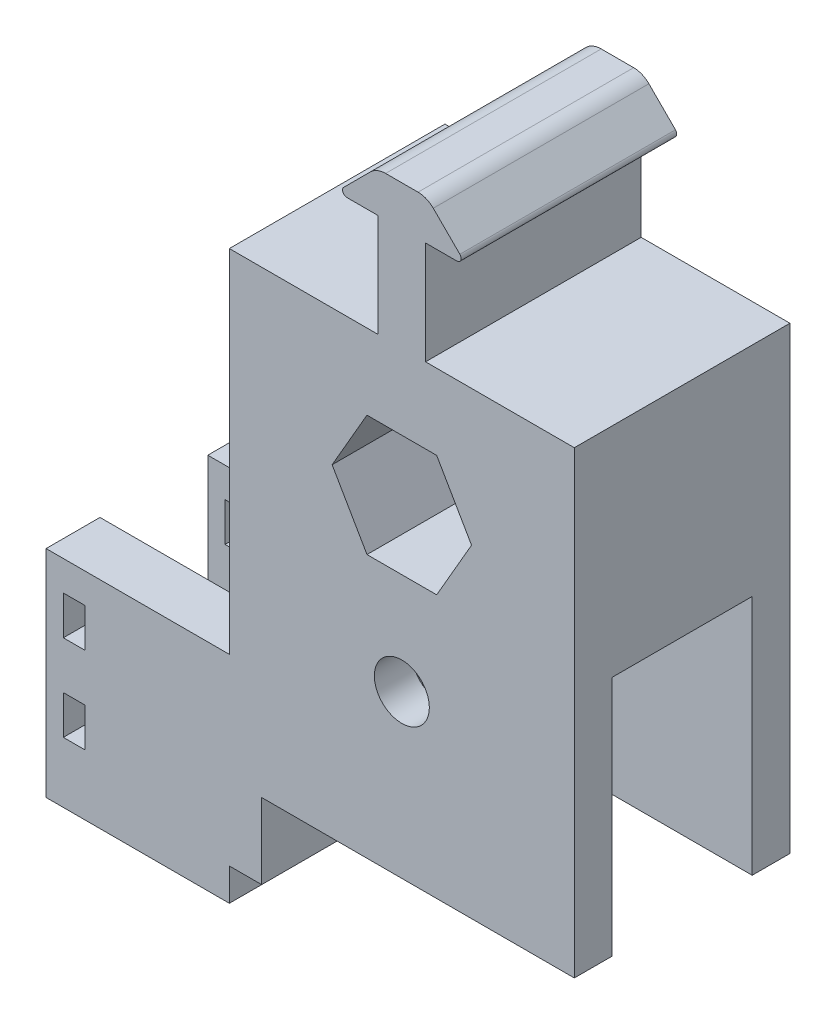
from build123d import *

# Parameters (mm, degrees)
BOSS_EXTRUDE1_DEPTH             = 12.7
BOSS_EXTRUDE4_REACH             = 14.7
BOSS_EXTRUDE4_DIRECTION_2_REACH = 14.7
SKETCH6_W                       = 16.51
SKETCH6_H                       = 15.748
CUT_EXTRUDE2_DEPTH              = 63.23
SKETCH11_W                      = 21.59
SKETCH11_H                      = 7.62
CUT_EXTRUDE3_DEPTH              = 3.81
SKETCH15_R                      = 3.2385
CUT_EXTRUDE4_DEPTH              = 25.4
SKETCH16_W                      = 16.51
SKETCH16_H                      = 12.7
CUT_EXTRUDE5_DEPTH              = 36.83
BOSS_EXTRUDE5_DEPTH             = 5.08
SKETCH18_W                      = 6.35
SKETCH18_H                      = 21.59
BOSS_EXTRUDE6_DEPTH             = 16.51
SKETCH22_W                      = 3.81
SKETCH22_H                      = 3.81
CUT_EXTRUDE6_DEPTH              = 25.4
SKETCH23_W                      = 2.54
SKETCH23_H                      = 4.572
CUT_EXTRUDE7_DEPTH              = 26.4


with BuildPart() as part:
    # Sketch1 → Boss-Extrude1 (new body, symmetric)
    with BuildSketch(Plane.XY):
        with BuildLine():
            Line((-20.32, 16.002), (-20.32, -38.1))
            Line((-20.32, -38.1), (20.32, -38.1))
            Line((20.32, -38.1), (20.32, 16.002))
            Line((20.32, 16.002), (2.794, 16.002))
            Line((2.794, 16.002), (2.794, 28.1305))
            Line((2.794, 28.1305), (6.477, 28.1305))
            ThreePointArc((6.477, 28.1305), (6.946330803, 28.444096816), (6.836210245, 28.997710245))
            Line((6.836210245, 28.997710245), (3.706459265, 32.127461224))
            ThreePointArc((3.706459265, 32.127461224), (2.882423959, 32.678064013), (1.910408041, 32.87141))
            Line((1.910408041, 32.87141), (-1.910408041, 32.87141))
            ThreePointArc((-1.910408041, 32.87141), (-2.882423959, 32.678064013), (-3.706459265, 32.127461224))
            Line((-3.706459265, 32.127461224), (-6.836210245, 28.997710245))
            ThreePointArc((-6.836210245, 28.997710245), (-6.946330803, 28.444096816), (-6.477, 28.1305))
            Line((-6.477, 28.1305), (-2.794, 28.1305))
            Line((-2.794, 28.1305), (-2.794, 16.002))
            Line((-2.794, 16.002), (-20.32, 16.002))
        make_face()
        Polygon((-4.106115114, 7.112), (-8.212230229, 0), (-4.106115114, -7.112), (4.106115114, -7.112), (8.212230229, 0), (4.106115114, 7.112), align=None, mode=Mode.SUBTRACT)
    extrude(amount=BOSS_EXTRUDE1_DEPTH, both=True)

    # Boss-Extrude4: up to this face of the body (flat: up to its plane)
    boss_extrude4_end = Plane(part.part.faces().sort_by_distance((0, -9.949298675, 12.7))[0])
    # Sketch10 → Boss-Extrude4 (add, up to the picked face)
    with BuildSketch(Plane.XY, mode=Mode.PRIVATE) as boss_extrude4_sk1:
        Polygon((-20.32, -38.1), (-20.32, -46.99), (-41.91, -46.99), (-41.91, -50.8), (-16.51, -50.8), (-16.51, -38.1), align=None)
    boss_extrude4_tool1 = split(extrude(boss_extrude4_sk1.sketch, amount=BOSS_EXTRUDE4_REACH, mode=Mode.PRIVATE), bisect_by=boss_extrude4_end, keep=Keep.BOTH, mode=Mode.PRIVATE)
    add(boss_extrude4_tool1.solids().sort_by_distance((-26.411296, -47.248704, 0))[0])

    # Boss-Extrude4 direction 2: up to this face of the body (flat: up to its plane)
    boss_extrude4_direction_2_end = Plane(part.part.faces().sort_by_distance((0, -9.949298675, -12.7))[0])
    # Sketch10 → Boss-Extrude4 direction 2 (add, up to the picked face)
    with BuildSketch(Plane.XY, mode=Mode.PRIVATE) as boss_extrude4_direction_2_sk1:
        Polygon((-20.32, -38.1), (-20.32, -46.99), (-41.91, -46.99), (-41.91, -50.8), (-16.51, -50.8), (-16.51, -38.1), align=None)
    boss_extrude4_direction_2_tool1 = split(extrude(boss_extrude4_direction_2_sk1.sketch, amount=-BOSS_EXTRUDE4_DIRECTION_2_REACH, mode=Mode.PRIVATE), bisect_by=boss_extrude4_direction_2_end, keep=Keep.BOTH, mode=Mode.PRIVATE)
    add(boss_extrude4_direction_2_tool1.solids().sort_by_distance((-26.411296, -47.248704, 0))[0])

    # Sketch6 → Cut-Extrude2 (cut, through all)
    with BuildSketch(Plane(origin=(20.32, 0, 0), x_dir=(0, 0, -1), z_dir=(1, 0, 0))):
        with Locations((0, -17.526)):
            Rectangle(SKETCH6_W, SKETCH6_H)
    extrude(amount=-CUT_EXTRUDE2_DEPTH, mode=Mode.SUBTRACT)

    # Sketch11 → Cut-Extrude3 (cut)
    with BuildSketch(Plane(origin=(0, -46.99, 0), x_dir=(1, 0, 0), z_dir=(0, 1, 0))):
        with Locations((-31.115, 0)):
            Rectangle(SKETCH11_W, SKETCH11_H)
    extrude(amount=-CUT_EXTRUDE3_DEPTH, mode=Mode.SUBTRACT)

    # Sketch15 → Cut-Extrude4 (cut)
    with BuildSketch(Plane.XY.offset(12.7)):
        with Locations((0, -19.05)):
            Circle(SKETCH15_R)
    extrude(amount=-CUT_EXTRUDE4_DEPTH, mode=Mode.SUBTRACT)

    # Sketch16 → Cut-Extrude5 (cut)
    with BuildSketch(Plane(origin=(20.32, 0, 0), x_dir=(0, 0, -1), z_dir=(1, 0, 0))):
        with Locations((0, -31.75)):
            Rectangle(SKETCH16_W, SKETCH16_H)
    extrude(amount=-CUT_EXTRUDE5_DEPTH, mode=Mode.SUBTRACT)

    # Sketch17 → Boss-Extrude5 (add)
    with BuildSketch(Plane.ZY.offset(20.32)):
        Polygon((12.7, -25.4), (12.7, -46.99), (3.81, -46.99), (3.81, -50.8), (-3.81, -50.8), (-3.81, -46.99), (-12.7, -46.99), (-12.7, -25.4), align=None)
    extrude(amount=BOSS_EXTRUDE5_DEPTH)

    # Sketch18 → Boss-Extrude6 (add)
    with BuildSketch(Plane.ZY.offset(25.4)):
        with Locations((-9.525, -36.195)):
            Rectangle(SKETCH18_W, SKETCH18_H)
        with Locations((9.525, -36.195)):
            Rectangle(SKETCH18_W, SKETCH18_H)
    extrude(amount=BOSS_EXTRUDE6_DEPTH)

    # Sketch22 → Cut-Extrude6 (cut)
    with BuildSketch(Plane.XY.offset(12.7)):
        with Locations((-18.415, -48.895)):
            Rectangle(SKETCH22_W, SKETCH22_H)
    extrude(amount=-CUT_EXTRUDE6_DEPTH, mode=Mode.SUBTRACT)

    # Sketch23 → Cut-Extrude7 (cut, through all)
    with BuildSketch(Plane.XY.offset(12.7)):
        with Locations((-38.608, -31.203491357)):
            Rectangle(SKETCH23_W, SKETCH23_H)
        with Locations((-38.608, -41.363491357)):
            Rectangle(SKETCH23_W, SKETCH23_H)
    extrude(amount=-CUT_EXTRUDE7_DEPTH, mode=Mode.SUBTRACT)


solid = part.part
